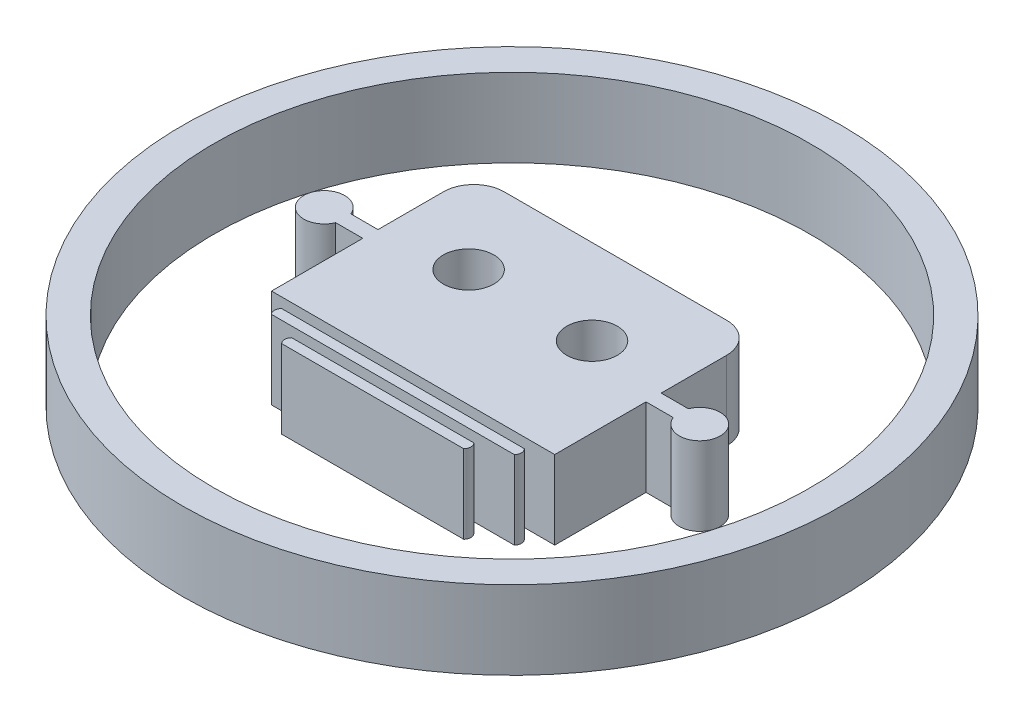
from build123d import *

# Parameters (mm, degrees)
SKETCH1_R             = 21
SKETCH1_R_2           = 19
BOSS_EXTRUDE1_DEPTH   = 5
SKETCH1_R_3           = 1.611255347
BOSS_EXTRUDE1_2_DEPTH = 5
BOSS_EXTRUDE1_3_DEPTH = 5
BOSS_EXTRUDE1_4_DEPTH = 5


with BuildPart() as part:
    # Sketch1 → Boss-Extrude1 (new body)
    with BuildSketch(Plane(origin=(0, 0, 0), x_dir=(1, 0, 0), z_dir=(0, 1, 0))):
        with Locations((-35.656522361, 86.864706092)):
            Circle(SKETCH1_R)
        with Locations((-35.656522361, 86.864706092)):
            Circle(SKETCH1_R_2, mode=Mode.SUBTRACT)
    extrude(amount=BOSS_EXTRUDE1_DEPTH)


with BuildPart() as body_2:
    # Sketch1 → Boss-Extrude1 2 (new body)
    with BuildSketch(Plane(origin=(0, 0, 0), x_dir=(1, 0, 0), z_dir=(0, 1, 0))):
        with BuildLine():
            Line((-26.633492417, 91.520801428), (-26.633492417, 87.348082696))
            Line((-26.633492417, 87.348082696), (-24.900858961, 87.348082696))
            ThreePointArc((-24.900858961, 87.348082696), (-22.38740856, 86.864706092), (-24.900858961, 86.381329488))
            Line((-24.900858961, 86.381329488), (-26.633492417, 86.381329488))
            Line((-26.633492417, 86.381329488), (-26.633492417, 80.564265068))
            Line((-26.633492417, 80.564265068), (-44.679552304, 80.564265068))
            Line((-44.679552304, 80.564265068), (-44.679552304, 86.381329488))
            Line((-44.679552304, 86.381329488), (-46.412185761, 86.381329488))
            ThreePointArc((-46.412185761, 86.381329488), (-48.925636161, 86.864706092), (-46.412185761, 87.348082696))
            Line((-46.412185761, 87.348082696), (-44.679552304, 87.348082696))
            Line((-44.679552304, 87.348082696), (-44.679552304, 91.520801428))
            ThreePointArc((-44.679552304, 91.520801428), (-44.113241386, 92.887996927), (-42.746045888, 93.454307845))
            Line((-42.746045888, 93.454307845), (-28.566998833, 93.454307845))
            ThreePointArc((-28.566998833, 93.454307845), (-27.199803335, 92.887996927), (-26.633492417, 91.520801428))
        make_face()
        with Locations((-39.588392261, 88.032660088)):
            Circle(SKETCH1_R_3, mode=Mode.SUBTRACT)
        with Locations((-31.72465246, 88.032660088)):
            Circle(SKETCH1_R_3, mode=Mode.SUBTRACT)
    extrude(amount=BOSS_EXTRUDE1_2_DEPTH)


with BuildPart() as body_3:
    # Sketch1 → Boss-Extrude1 3 (new body)
    with BuildSketch(Plane(origin=(0, 0, 0), x_dir=(1, 0, 0), z_dir=(0, 1, 0))):
        with BuildLine():
            ThreePointArc((-29.856003111, 78.630758651), (-29.722522348, 78.308507582), (-29.856003111, 77.986256512))
            Line((-29.856003111, 77.986256512), (-41.45704161, 77.986256512))
            ThreePointArc((-41.45704161, 77.986256512), (-41.590522374, 78.308507582), (-41.45704161, 78.630758651))
            Line((-41.45704161, 78.630758651), (-29.856003111, 78.630758651))
        make_face()
    extrude(amount=BOSS_EXTRUDE1_3_DEPTH)


with BuildPart() as body_4:
    # Sketch1 → Boss-Extrude1 4 (new body)
    with BuildSketch(Plane(origin=(0, 0, 0), x_dir=(1, 0, 0), z_dir=(0, 1, 0))):
        with BuildLine():
            ThreePointArc((-27.922496694, 79.919762929), (-27.789015931, 79.597511859), (-27.922496694, 79.27526079))
            Line((-27.922496694, 79.27526079), (-43.390548027, 79.27526079))
            ThreePointArc((-43.390548027, 79.27526079), (-43.52402879, 79.597511859), (-43.390548027, 79.919762929))
            Line((-43.390548027, 79.919762929), (-27.922496694, 79.919762929))
        make_face()
    extrude(amount=BOSS_EXTRUDE1_4_DEPTH)


solid = Compound([part.part, body_2.part, body_3.part, body_4.part])
